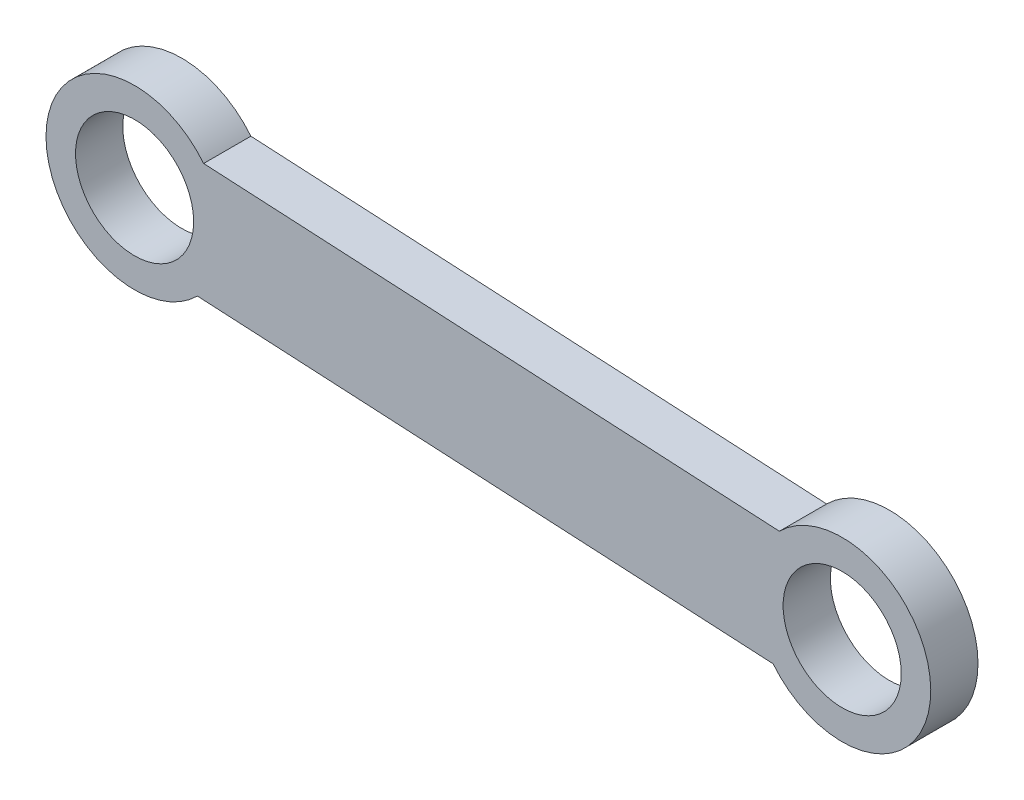
from build123d import *

# Parameters (mm, degrees)
BOSS_EXTRUDE1_DEPTH = 4


with BuildPart() as part:
    # Sketch1 → Boss-Extrude1 (new body)
    with BuildSketch(Plane(origin=(0, 0, 0), x_dir=(0.431181775, 0.902265081, 0), z_dir=(0, 0, 1))):
        with BuildLine():
            ThreePointArc((-30.032895054, 31.515538639), (-26.144357712, 35.193408701), (-20.794099729, 35.342372963))
            Line((-20.794099729, 35.342372963), (-39.476574827, 80.445857725))
            ThreePointArc((-39.476574827, 80.445857725), (-43.365112169, 76.767987664), (-48.715370152, 76.619023401))
            Line((-48.715370152, 76.619023401), (-30.032895054, 31.515538639))
        make_face()
        with BuildLine():
            ThreePointArc((-48.715370152, 76.619023401), (-43.365112169, 76.767987664), (-39.476574827, 80.445857725))
            Line((-39.476574827, 80.445857725), (-41.615840249, 85.610501319))
            ThreePointArc((-41.615840249, 85.610501319), (-41.331311509, 84.672535768), (-41.235237911, 83.697084158))
            ThreePointArc((-41.235237911, 83.697084158), (-45.259786301, 78.793157756), (-50.854635574, 81.783666996))
            Line((-50.854635574, 81.783666996), (-48.715370152, 76.619023401))
        make_face()
        with BuildLine():
            Line((-41.615840249, 85.610501319), (-39.476574827, 80.445857725))
            ThreePointArc((-39.476574827, 80.445857725), (-38.922920456, 82.029746929), (-38.735237911, 83.697084158))
            ThreePointArc((-38.735237911, 83.697084158), (-50.573959393, 89.814722256), (-48.715370152, 76.619023401))
            Line((-48.715370152, 76.619023401), (-50.854635574, 81.783666996))
            ThreePointArc((-50.854635574, 81.783666996), (-48.148655073, 88.31648182), (-41.615840249, 85.610501319))
        make_face()
        with BuildLine():
            Line((-20.794099729, 35.342372963), (-18.654834307, 30.177729369))
            ThreePointArc((-18.654834307, 30.177729369), (-18.370305568, 29.239763817), (-18.27423197, 28.264312207))
            ThreePointArc((-18.27423197, 28.264312207), (-22.298780359, 23.360385805), (-27.893629632, 26.350895045))
            Line((-27.893629632, 26.350895045), (-30.032895054, 31.515538639))
            ThreePointArc((-30.032895054, 31.515538639), (-24.941569198, 20.951994752), (-15.77423197, 28.264312207))
            ThreePointArc((-15.77423197, 28.264312207), (-17.156593871, 32.603033689), (-20.794099729, 35.342372963))
        make_face()
        with BuildLine():
            ThreePointArc((-27.893629632, 26.350895045), (-25.187649131, 32.883709869), (-18.654834307, 30.177729369))
            Line((-18.654834307, 30.177729369), (-20.794099729, 35.342372963))
            ThreePointArc((-20.794099729, 35.342372963), (-26.144357712, 35.193408701), (-30.032895054, 31.515538639))
            Line((-30.032895054, 31.515538639), (-27.893629632, 26.350895045))
        make_face()
    extrude(amount=BOSS_EXTRUDE1_DEPTH)


solid = part.part
